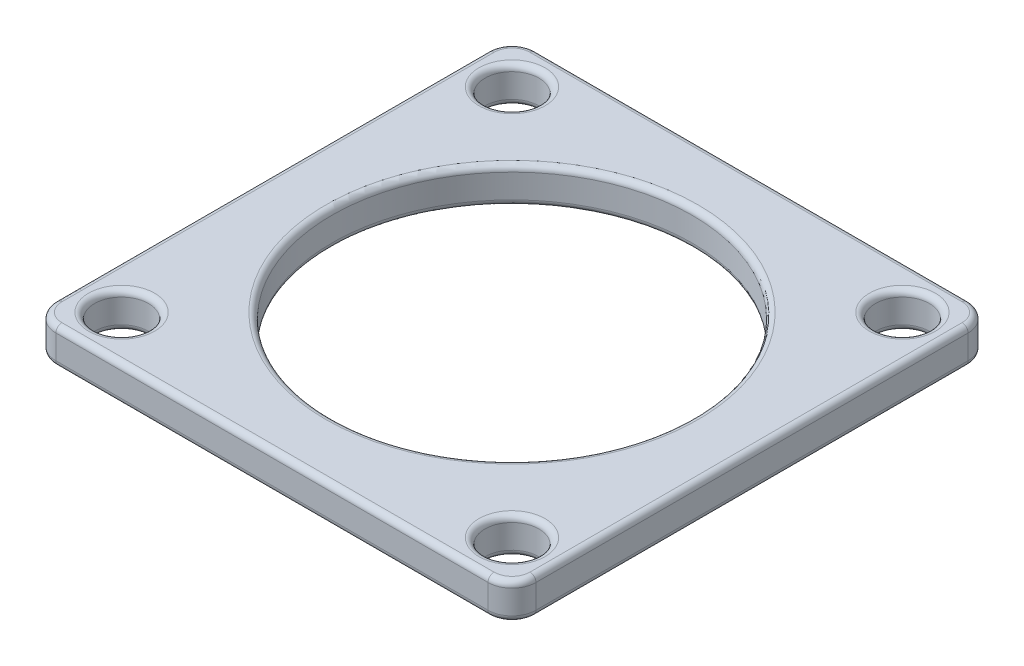
from build123d import *

# Parameters (mm, degrees)
SKETCH1_R           = 2.25
SKETCH1_R_2         = 15
BOSS_EXTRUDE1_DEPTH = 3
FILLET1_R           = 0.5


with BuildPart() as part:
    # Sketch1 → Boss-Extrude1 (new body)
    with BuildSketch(Plane(origin=(0, 0, 0), x_dir=(1, 0, 0), z_dir=(0, 1, 0))):
        with BuildLine():
            Line((-18, 20), (18, 20))
            ThreePointArc((18, 20), (19.414213562, 19.414213562), (20, 18))
            Line((20, 18), (20, -18))
            ThreePointArc((20, -18), (19.414213562, -19.414213562), (18, -20))
            Line((18, -20), (-18, -20))
            ThreePointArc((-18, -20), (-19.414213562, -19.414213562), (-20, -18))
            Line((-20, -18), (-20, 18))
            ThreePointArc((-20, 18), (-19.414213562, 19.414213562), (-18, 20))
        make_face()
        with Locations((-16.263455967, 16.263455967)):
            Circle(SKETCH1_R, mode=Mode.SUBTRACT)
        with Locations((16.263455967, 16.263455967)):
            Circle(SKETCH1_R, mode=Mode.SUBTRACT)
        with Locations((16.263455967, -16.263455967)):
            Circle(SKETCH1_R, mode=Mode.SUBTRACT)
        with Locations((-16.263455967, -16.263455967)):
            Circle(SKETCH1_R, mode=Mode.SUBTRACT)
        Circle(SKETCH1_R_2, mode=Mode.SUBTRACT)
    extrude(amount=BOSS_EXTRUDE1_DEPTH)

    # Fillet1
    fillet1_edges = [part.edges().sort_by_distance(p)[0] for p in [
        (0, 0, -20),
        (19.414213562, 0, -19.414213562),
        (20, 0, 0),
        (19.414213562, 0, 19.414213562),
        (19.414213562, 3, -19.414213562),
        (0, 3, -20),
        (-19.414213562, 3, -19.414213562),
        (-18.513455967, 0, -16.263455967),
        (-18.513455967, 3, -16.263455967),
        (-20, 3, 0),
        (14.013455967, 0, -16.263455967),
        (14.013455967, 3, -16.263455967),
        (-19.414213562, 3, 19.414213562),
        (14.013455967, 0, 16.263455967),
        (14.013455967, 3, 16.263455967),
        (0, 3, 20),
        (-18.513455967, 0, 16.263455967),
        (-18.513455967, 3, 16.263455967),
        (-15, 0, 0),
        (-15, 3, 0),
        (19.414213562, 3, 19.414213562),
        (0, 0, 20),
        (20, 3, 0),
        (-19.414213562, 0, 19.414213562),
        (-20, 0, 0),
        (-19.414213562, 0, -19.414213562),
    ]]
    fillet(fillet1_edges, radius=FILLET1_R)


solid = part.part
